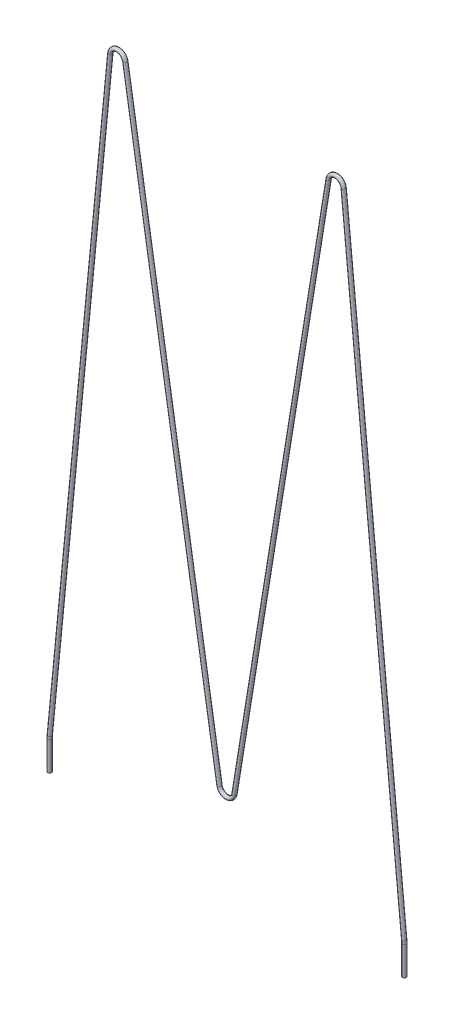
from build123d import *

# Parameters (mm, degrees)
SKETCH2_R = 0.125


with BuildPart() as part:
    # Sweep1: sweep along a path in Sketch1
    with BuildLine(Plane.XY) as sweep1_path:
        Line((-11.7, 12), (-11.7, 13.902727498))
        ThreePointArc((-11.7, 13.902727498), (-11.697638703, 13.999885155), (-11.69056039, 14.096813395))
        Line((-11.69056039, 14.096813395), (-7.697640097, 55.048521474))
        ThreePointArc((-7.697640097, 55.048521474), (-7.215943493, 55.49974574), (-6.706464717, 55.080143151))
        Line((-6.706464717, 55.080143151), (-0.493535283, 16.819856849))
        ThreePointArc((-0.493535283, 16.819856849), (0, 16.4), (0.493535283, 16.819856849))
        Line((0.493535283, 16.819856849), (6.706464717, 55.080143151))
        ThreePointArc((6.706464717, 55.080143151), (7.215943493, 55.49974574), (7.697640097, 55.048521474))
        Line((7.697640097, 55.048521474), (11.69056039, 14.096813395))
        ThreePointArc((11.69056039, 14.096813395), (11.697638703, 13.999885155), (11.7, 13.902727498))
        Line((11.7, 13.902727498), (11.7, 12))
    # Sketch2 → Sweep1 (sweep)
    with BuildSketch(Plane(origin=(0, 12, 0), x_dir=(-1, 0, 0), z_dir=(0, 1, 0))):
        with Locations((11.7, 0)):
            Circle(SKETCH2_R)
    sweep(path=sweep1_path.line)


solid = part.part
